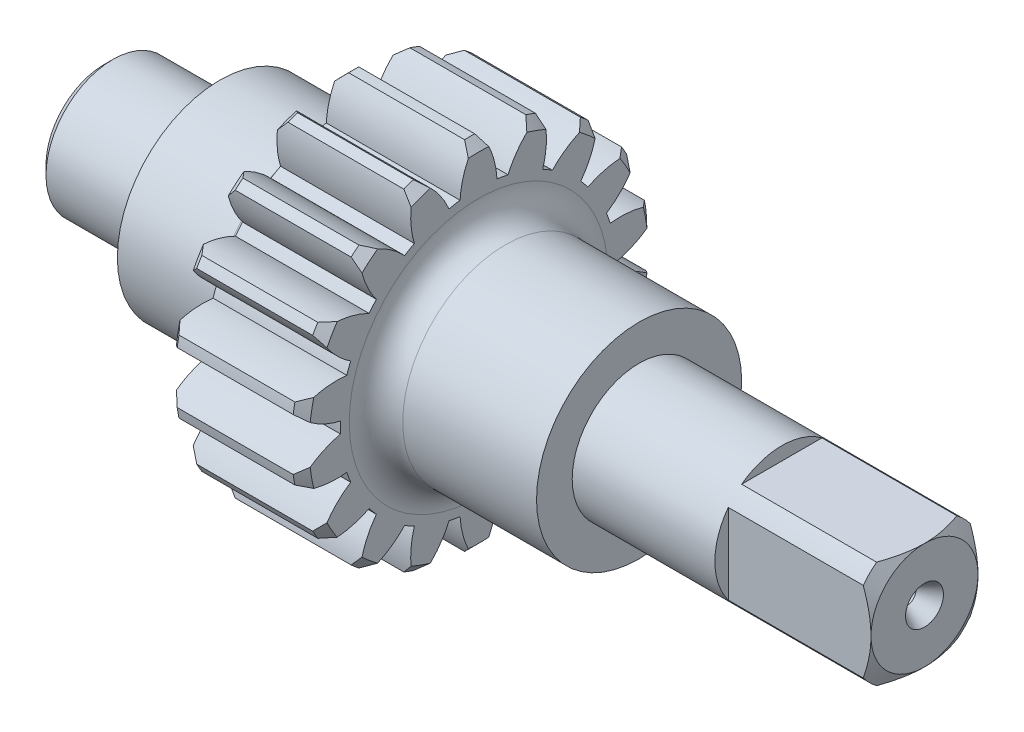
from build123d import *

# Parameters (mm, degrees)
BOSS_EXTRUDE1_DEPTH = 15
CHAMFER1_SIZE       = 1
CHAMFER2_SIZE       = 1.5
CHAMFER2_SIZE2      = 0.866025404
CUT_EXTRUDE2_DEPTH  = 16
CHAMFER3_SIZE       = 1
CHAMFER4_SIZE       = 1


with BuildPart() as part:
    # Sketch2 → Revolve1 (revolve)
    with BuildSketch(Plane.XY):
        with BuildLine():
            Line((27, 15.5), (27, 14.5))
            ThreePointArc((27, 14.5), (26.121320344, 12.378679656), (24, 11.5))
            Line((24, 11.5), (13, 11.5))
            Line((13, 11.5), (13, 7.5))
            Line((13, 7.5), (0, 7.5))
            Line((0, 7.5), (0, 0))
            Line((0, 0), (92, 0))
            Line((92, 0), (92, 7.5))
            Line((92, 7.5), (60, 7.5))
            Line((60, 7.5), (60, 11.5))
            Line((60, 11.5), (45, 11.5))
            ThreePointArc((45, 11.5), (42.878679656, 12.378679656), (42, 14.5))
            Line((42, 14.5), (42, 15.5))
            Line((42, 15.5), (27, 15.5))
        make_face()
    revolve(axis=Axis((0, 0, 0), (1, 0, 0)))

    # Sketch3 → Boss-Extrude1 (add)
    with BuildSketch(Plane(origin=(42, 0, 0), x_dir=(0, 0, -1), z_dir=(1, 0, 0))):
        with BuildLine():
            ThreePointArc((0.57, 19.99187585), (0, 20), (-0.57, 19.99187585))
            add(Edge.make_bspline(
                [(-0.57, 19.99187585), (-1.922955877, 17.877659072), (-2.07, 15.361155555)],
                knots=[0, 0, 0, 1, 1, 1], degree=2))
            ThreePointArc((-2.07, 15.361155555), (0, 15.5), (2.07, 15.361155555))
            add(Edge.make_bspline(
                [(0.57, 19.99187585), (1.922955877, 17.877659072), (2.07, 15.361155555)],
                knots=[0, 0, 0, 1, 1, 1], degree=2))
        make_face()
        with BuildLine():
            ThreePointArc((7.19898835, 13.726782826), (5.301312222, 14.565235622), (3.3086609, 15.142746219))
            add(Edge.make_bspline(
                [(6.30199945, 18.981169694), (4.307532071, 17.457193951), (3.3086609, 15.142746219)],
                knots=[0, 0, 0, 1, 1, 1], degree=2))
            ThreePointArc((6.30199945, 18.981169694), (6.840402867, 18.793852416), (7.373249037, 18.59126673))
            add(Edge.make_bspline(
                [(7.373249037, 18.59126673), (7.921506965, 16.141814662), (7.19898835, 13.726782826)],
                knots=[0, 0, 0, 1, 1, 1], degree=2))
        make_face()
        with BuildLine():
            ThreePointArc((11.459672459, 10.436757501), (9.96320795, 11.873688868), (8.288248464, 13.097898205))
            add(Edge.make_bspline(
                [(12.413884758, 15.68105434), (10.018468078, 14.931133599), (8.288248464, 13.097898205)],
                knots=[0, 0, 0, 1, 1, 1], degree=2))
            ThreePointArc((12.413884758, 15.68105434), (12.855752194, 15.320888862), (13.287175423, 14.948276465))
            add(Edge.make_bspline(
                [(13.287175423, 14.948276465), (12.964607405, 12.459029177), (11.459672459, 10.436757501)],
                knots=[0, 0, 0, 1, 1, 1], degree=2))
        make_face()
        with BuildLine():
            ThreePointArc((14.338150943, 5.887905192), (13.423393759, 7.75), (12.268150943, 9.473250364))
            add(Edge.make_bspline(
                [(17.028472355, 10.489572405), (14.521028978, 10.604158175), (12.268150943, 9.473250364)],
                knots=[0, 0, 0, 1, 1, 1], degree=2))
            ThreePointArc((17.028472355, 10.489572405), (17.320508076, 10), (17.598472355, 9.502303445))
            add(Edge.make_bspline(
                [(17.598472355, 9.502303445), (16.443984855, 7.273500897), (14.338150943, 5.887905192)],
                knots=[0, 0, 0, 1, 1, 1], degree=2))
        make_face()
        with BuildLine():
            ThreePointArc((15.487236814, 0.62888462), (15.264520172, 2.691546754), (14.768333359, 4.705988718))
            add(Edge.make_bspline(
                [(19.589174873, 4.032893229), (17.272139476, 4.998164775), (14.768333359, 4.705988718)],
                knots=[0, 0, 0, 1, 1, 1], degree=2))
            ThreePointArc((19.589174873, 4.032893229), (19.69615506, 3.472963553), (19.787133796, 2.91021239))
            add(Edge.make_bspline(
                [(19.787133796, 2.91021239), (17.939975043, 1.210681063), (15.487236814, 0.62888462)],
                knots=[0, 0, 0, 1, 1, 1], degree=2))
        make_face()
        with BuildLine():
            ThreePointArc((14.768333359, -4.705988718), (15.264520172, -2.691546754), (15.487236814, -0.62888462))
            add(Edge.make_bspline(
                [(19.787133796, -2.91021239), (17.939975043, -1.210681063), (15.487236814, -0.62888462)],
                knots=[0, 0, 0, 1, 1, 1], degree=2))
            ThreePointArc((19.787133796, -2.91021239), (19.69615506, -3.472963553), (19.589174873, -4.032893229))
            add(Edge.make_bspline(
                [(19.589174873, -4.032893229), (17.272139476, -4.998164775), (14.768333359, -4.705988718)],
                knots=[0, 0, 0, 1, 1, 1], degree=2))
        make_face()
        with BuildLine():
            ThreePointArc((12.268150943, -9.473250364), (13.423393759, -7.75), (14.338150943, -5.887905192))
            add(Edge.make_bspline(
                [(17.598472355, -9.502303445), (16.443984855, -7.273500897), (14.338150943, -5.887905192)],
                knots=[0, 0, 0, 1, 1, 1], degree=2))
            ThreePointArc((17.598472355, -9.502303445), (17.320508076, -10), (17.028472355, -10.489572405))
            add(Edge.make_bspline(
                [(17.028472355, -10.489572405), (14.521028978, -10.604158175), (12.268150943, -9.473250364)],
                knots=[0, 0, 0, 1, 1, 1], degree=2))
        make_face()
        with BuildLine():
            ThreePointArc((8.288248464, -13.097898205), (9.96320795, -11.873688868), (11.459672459, -10.436757501))
            add(Edge.make_bspline(
                [(13.287175423, -14.948276465), (12.964607405, -12.459029177), (11.459672459, -10.436757501)],
                knots=[0, 0, 0, 1, 1, 1], degree=2))
            ThreePointArc((13.287175423, -14.948276465), (12.855752194, -15.320888862), (12.413884758, -15.68105434))
            add(Edge.make_bspline(
                [(12.413884758, -15.68105434), (10.018468078, -14.931133599), (8.288248464, -13.097898205)],
                knots=[0, 0, 0, 1, 1, 1], degree=2))
        make_face()
        with BuildLine():
            ThreePointArc((3.3086609, -15.142746219), (5.301312222, -14.565235622), (7.19898835, -13.726782826))
            add(Edge.make_bspline(
                [(7.373249037, -18.59126673), (7.921506965, -16.141814662), (7.19898835, -13.726782826)],
                knots=[0, 0, 0, 1, 1, 1], degree=2))
            ThreePointArc((7.373249037, -18.59126673), (6.840402867, -18.793852416), (6.30199945, -18.981169694))
            add(Edge.make_bspline(
                [(6.30199945, -18.981169694), (4.307532071, -17.457193951), (3.3086609, -15.142746219)],
                knots=[0, 0, 0, 1, 1, 1], degree=2))
        make_face()
        with BuildLine():
            ThreePointArc((-2.07, -15.361155555), (0, -15.5), (2.07, -15.361155555))
            add(Edge.make_bspline(
                [(0.57, -19.99187585), (1.922955877, -17.877659072), (2.07, -15.361155555)],
                knots=[0, 0, 0, 1, 1, 1], degree=2))
            ThreePointArc((0.57, -19.99187585), (0, -20), (-0.57, -19.99187585))
            add(Edge.make_bspline(
                [(-0.57, -19.99187585), (-1.922955877, -17.877659072), (-2.07, -15.361155555)],
                knots=[0, 0, 0, 1, 1, 1], degree=2))
        make_face()
        with BuildLine():
            ThreePointArc((-7.19898835, -13.726782826), (-5.301312222, -14.565235622), (-3.3086609, -15.142746219))
            add(Edge.make_bspline(
                [(-6.30199945, -18.981169694), (-4.307532071, -17.457193951), (-3.3086609, -15.142746219)],
                knots=[0, 0, 0, 1, 1, 1], degree=2))
            ThreePointArc((-6.30199945, -18.981169694), (-6.840402867, -18.793852416), (-7.373249037, -18.59126673))
            add(Edge.make_bspline(
                [(-7.373249037, -18.59126673), (-7.921506965, -16.141814662), (-7.19898835, -13.726782826)],
                knots=[0, 0, 0, 1, 1, 1], degree=2))
        make_face()
        with BuildLine():
            ThreePointArc((-11.459672459, -10.436757501), (-9.96320795, -11.873688868), (-8.288248464, -13.097898205))
            add(Edge.make_bspline(
                [(-12.413884758, -15.68105434), (-10.018468078, -14.931133599), (-8.288248464, -13.097898205)],
                knots=[0, 0, 0, 1, 1, 1], degree=2))
            ThreePointArc((-12.413884758, -15.68105434), (-12.855752194, -15.320888862), (-13.287175423, -14.948276465))
            add(Edge.make_bspline(
                [(-13.287175423, -14.948276465), (-12.964607405, -12.459029177), (-11.459672459, -10.436757501)],
                knots=[0, 0, 0, 1, 1, 1], degree=2))
        make_face()
        with BuildLine():
            ThreePointArc((-14.338150943, -5.887905192), (-13.423393759, -7.75), (-12.268150943, -9.473250364))
            add(Edge.make_bspline(
                [(-17.028472355, -10.489572405), (-14.521028978, -10.604158175), (-12.268150943, -9.473250364)],
                knots=[0, 0, 0, 1, 1, 1], degree=2))
            ThreePointArc((-17.028472355, -10.489572405), (-17.320508076, -10), (-17.598472355, -9.502303445))
            add(Edge.make_bspline(
                [(-17.598472355, -9.502303445), (-16.443984855, -7.273500897), (-14.338150943, -5.887905192)],
                knots=[0, 0, 0, 1, 1, 1], degree=2))
        make_face()
        with BuildLine():
            ThreePointArc((-15.487236814, -0.62888462), (-15.264520172, -2.691546754), (-14.768333359, -4.705988718))
            add(Edge.make_bspline(
                [(-19.589174873, -4.032893229), (-17.272139476, -4.998164775), (-14.768333359, -4.705988718)],
                knots=[0, 0, 0, 1, 1, 1], degree=2))
            ThreePointArc((-19.589174873, -4.032893229), (-19.69615506, -3.472963553), (-19.787133796, -2.91021239))
            add(Edge.make_bspline(
                [(-19.787133796, -2.91021239), (-17.939975043, -1.210681063), (-15.487236814, -0.62888462)],
                knots=[0, 0, 0, 1, 1, 1], degree=2))
        make_face()
        with BuildLine():
            ThreePointArc((-14.768333359, 4.705988718), (-15.264520172, 2.691546754), (-15.487236814, 0.62888462))
            add(Edge.make_bspline(
                [(-19.787133796, 2.91021239), (-17.939975043, 1.210681063), (-15.487236814, 0.62888462)],
                knots=[0, 0, 0, 1, 1, 1], degree=2))
            ThreePointArc((-19.787133796, 2.91021239), (-19.69615506, 3.472963553), (-19.589174873, 4.032893229))
            add(Edge.make_bspline(
                [(-19.589174873, 4.032893229), (-17.272139476, 4.998164775), (-14.768333359, 4.705988718)],
                knots=[0, 0, 0, 1, 1, 1], degree=2))
        make_face()
        with BuildLine():
            ThreePointArc((-12.268150943, 9.473250364), (-13.423393759, 7.75), (-14.338150943, 5.887905192))
            add(Edge.make_bspline(
                [(-17.598472355, 9.502303445), (-16.443984855, 7.273500897), (-14.338150943, 5.887905192)],
                knots=[0, 0, 0, 1, 1, 1], degree=2))
            ThreePointArc((-17.598472355, 9.502303445), (-17.320508076, 10), (-17.028472355, 10.489572405))
            add(Edge.make_bspline(
                [(-17.028472355, 10.489572405), (-14.521028978, 10.604158175), (-12.268150943, 9.473250364)],
                knots=[0, 0, 0, 1, 1, 1], degree=2))
        make_face()
        with BuildLine():
            ThreePointArc((-8.288248464, 13.097898205), (-9.96320795, 11.873688868), (-11.459672459, 10.436757501))
            add(Edge.make_bspline(
                [(-13.287175423, 14.948276465), (-12.964607405, 12.459029177), (-11.459672459, 10.436757501)],
                knots=[0, 0, 0, 1, 1, 1], degree=2))
            ThreePointArc((-13.287175423, 14.948276465), (-12.855752194, 15.320888862), (-12.413884758, 15.68105434))
            add(Edge.make_bspline(
                [(-12.413884758, 15.68105434), (-10.018468078, 14.931133599), (-8.288248464, 13.097898205)],
                knots=[0, 0, 0, 1, 1, 1], degree=2))
        make_face()
        with BuildLine():
            ThreePointArc((-3.3086609, 15.142746219), (-5.301312222, 14.565235622), (-7.19898835, 13.726782826))
            add(Edge.make_bspline(
                [(-7.373249037, 18.59126673), (-7.921506965, 16.141814662), (-7.19898835, 13.726782826)],
                knots=[0, 0, 0, 1, 1, 1], degree=2))
            ThreePointArc((-7.373249037, 18.59126673), (-6.840402867, 18.793852416), (-6.30199945, 18.981169694))
            add(Edge.make_bspline(
                [(-6.30199945, 18.981169694), (-4.307532071, 17.457193951), (-3.3086609, 15.142746219)],
                knots=[0, 0, 0, 1, 1, 1], degree=2))
        make_face()
    extrude(amount=-BOSS_EXTRUDE1_DEPTH)

    # Sketch4 → Cut-Revolve1 (revolve, cut)
    with BuildSketch(Plane(origin=(0, 0, 0), x_dir=(1, 0, 0), z_dir=(0, 1, 0))):
        Polygon((86.75, 0), (92, 0), (92, 2.125833025), (90.05, 1), (88.25, 1), align=None)
        Polygon((5.25, 0), (0, 0), (0, 2.125833025), (1.95, 1), (3.75, 1), align=None)
    revolve(axis=Axis((92, 0, 0), (-1, 0, 0)), mode=Mode.SUBTRACT)

    # Chamfer1
    chamfer1_edges = [part.edges().sort_by_distance(p)[0] for p in [
        (0, -7.5, 0),
    ]]
    chamfer(chamfer1_edges, length=CHAMFER1_SIZE)

    # Chamfer2
    chamfer2_edges = [part.edges().sort_by_distance(p)[0] for p in [
        (92, -7.5, 0),
    ]]
    chamfer2_side = [part.faces().sort_by_distance(p)[0] for p in [
        (92, -7.287867966, 0),
    ]]
    chamfer(chamfer2_edges, length=CHAMFER2_SIZE, length2=CHAMFER2_SIZE2, reference=chamfer2_side[0])

    # Sketch7 → Cut-Extrude2 (cut)
    with BuildSketch(Plane(origin=(92, 0, 0), x_dir=(0, 0, -1), z_dir=(1, 0, 0))):
        Polygon((0, 11), (6, 6), (-6, 6), align=None)
        Polygon((6, 6), (11, 0), (6, -6), align=None)
        Polygon((-6, -6), (-11, 0), (-6, 6), align=None)
        Polygon((6, -6), (0, -11), (-6, -6), align=None)
    extrude(amount=-CUT_EXTRUDE2_DEPTH, mode=Mode.SUBTRACT)

    # Chamfer3
    chamfer3_edges = [part.edges().sort_by_distance(p)[0] for p in [
        (42, -18.793852416, -6.840402867),
        (42, -15.320888862, -12.855752194),
        (42, -10, -17.320508076),
        (42, -3.472963553, -19.69615506),
        (42, 3.472963553, -19.69615506),
        (42, 10, -17.320508076),
        (42, 15.320888862, -12.855752194),
        (42, 18.793852416, -6.840402867),
        (42, 20, 0),
        (42, 18.793852416, 6.840402867),
        (42, 15.320888862, 12.855752194),
        (42, 10, 17.320508076),
        (42, 3.472963553, 19.69615506),
        (42, -3.472963553, 19.69615506),
        (42, -10, 17.320508076),
        (42, -20, 0),
        (42, -18.793852416, 6.840402867),
        (42, -15.320888862, 12.855752194),
    ]]
    chamfer(chamfer3_edges, length=CHAMFER3_SIZE)

    # Chamfer4
    chamfer4_edges = [part.edges().sort_by_distance(p)[0] for p in [
        (27, -18.793852416, -6.840402867),
        (27, -20, 0),
        (27, -18.793852416, 6.840402867),
        (27, -15.320888862, 12.855752194),
        (27, -10, 17.320508076),
        (27, -3.472963553, 19.69615506),
        (27, 3.472963553, 19.69615506),
        (27, 10, 17.320508076),
        (27, 15.320888862, 12.855752194),
        (27, 18.793852416, 6.840402867),
        (27, 20, 0),
        (27, 18.793852416, -6.840402867),
        (27, 15.320888862, -12.855752194),
        (27, 10, -17.320508076),
        (27, 3.472963553, -19.69615506),
        (27, -15.320888862, -12.855752194),
        (27, -3.472963553, -19.69615506),
        (27, -10, -17.320508076),
    ]]
    chamfer(chamfer4_edges, length=CHAMFER4_SIZE)


solid = part.part
